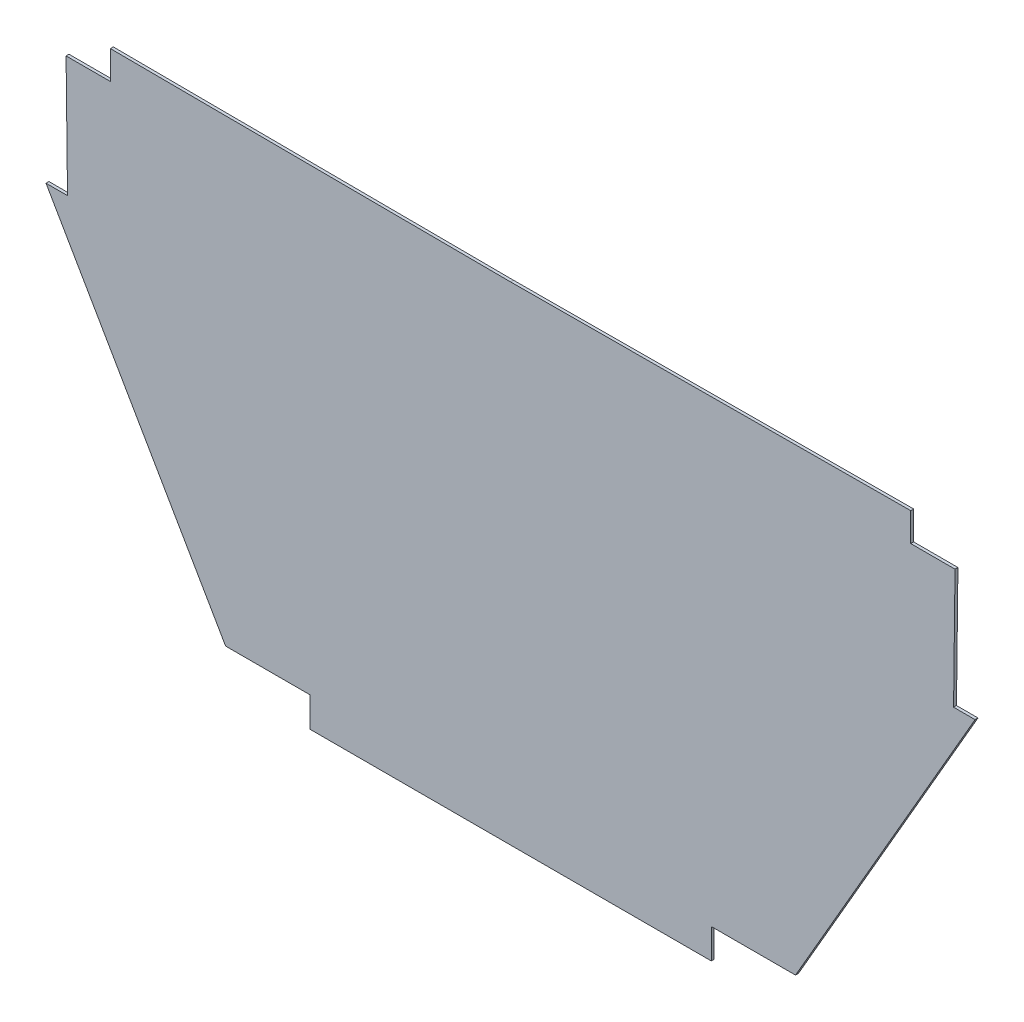
from build123d import *

# Parameters (mm, degrees)
BOSS_EXTRUDE1_DEPTH = 2


with BuildPart() as part:
    # Sketch1 → Boss-Extrude1 (new body)
    with BuildSketch(Plane.XY):
        Polygon((200.633041838, 424.095322805), (185.831141678, 424.095322805), (309.377353743, 210.107006425), (367.2941201, 210.107006425), (367.2941201, 189.577029057), (643.515652788, 189.577029057), (643.515652788, 210.107006425), (701.432419146, 210.107006425), (824.978631211, 424.095322805), (810.17673105, 424.095322805), (811.168094525, 506.846953045), (780.693298387, 506.846953045), (780.693298387, 526.455448064), (505.404886444, 525.086811412), (230.116474501, 526.455448064), (230.116474501, 506.846953045), (199.641678363, 506.846953045), align=None)
    extrude(amount=BOSS_EXTRUDE1_DEPTH)


solid = part.part
